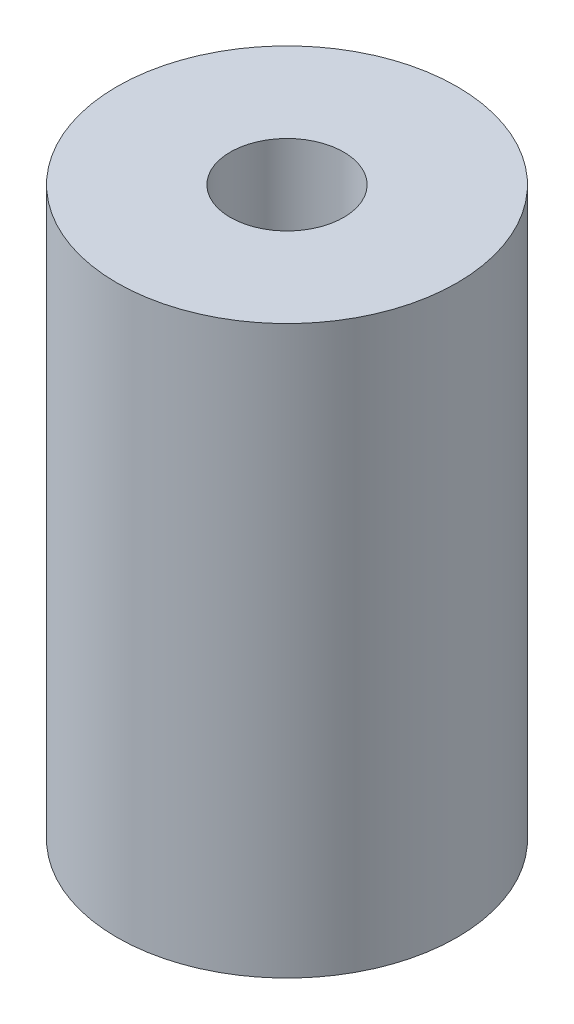
from build123d import *

# Parameters (mm, degrees)
SKETCH1_R           = 9.525
SKETCH1_R_2         = 3.175
BOSS_EXTRUDE1_DEPTH = 31.75


with BuildPart() as part:
    # Sketch1 → Boss-Extrude1 (new body)
    with BuildSketch(Plane(origin=(0, 0, 0), x_dir=(1, 0, 0), z_dir=(0, 1, 0))):
        Circle(SKETCH1_R)
        Circle(SKETCH1_R_2, mode=Mode.SUBTRACT)
    extrude(amount=BOSS_EXTRUDE1_DEPTH)


solid = part.part
